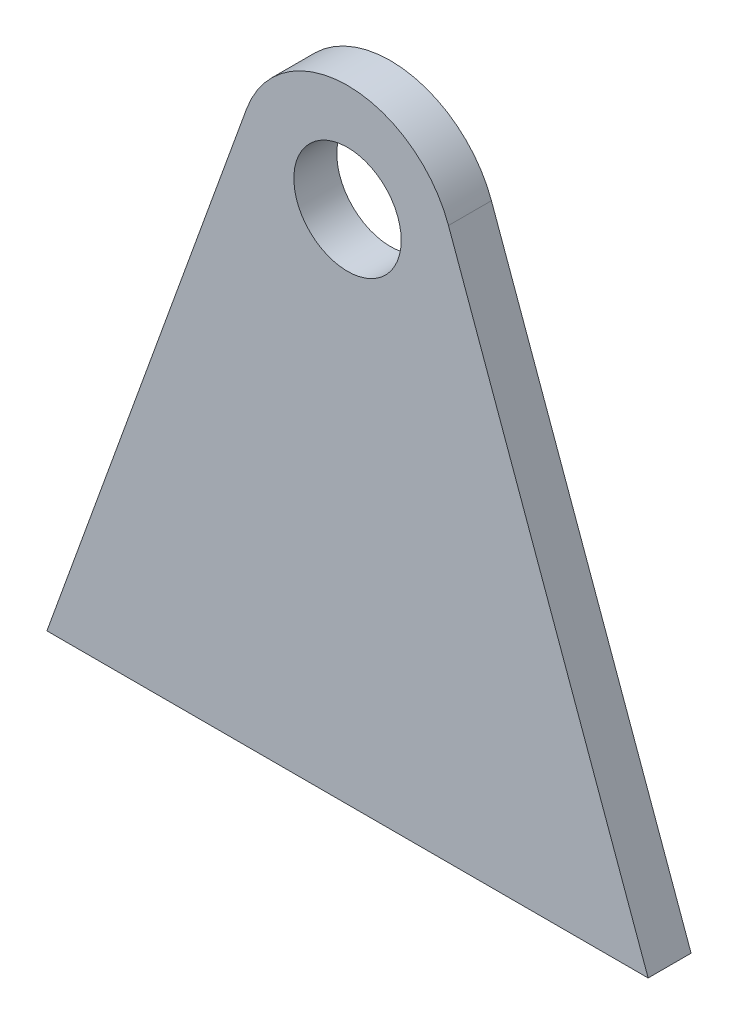
from build123d import *

# Parameters (mm, degrees)
SKETCH1_R           = 25
BOSS_EXTRUDE1_DEPTH = 20


with BuildPart() as part:
    # Sketch1 → Boss-Extrude1 (new body)
    with BuildSketch(Plane.XY):
        with BuildLine():
            Line((-140, 0), (140, 0))
            Line((140, 0), (47.017565913, 257.010246783))
            ThreePointArc((47.017565913, 257.010246783), (0, 290), (-47.017565913, 257.010246783))
            Line((-47.017565913, 257.010246783), (-140, 0))
        make_face()
        with Locations((0, 240)):
            Circle(SKETCH1_R, mode=Mode.SUBTRACT)
    extrude(amount=-BOSS_EXTRUDE1_DEPTH)


solid = part.part
